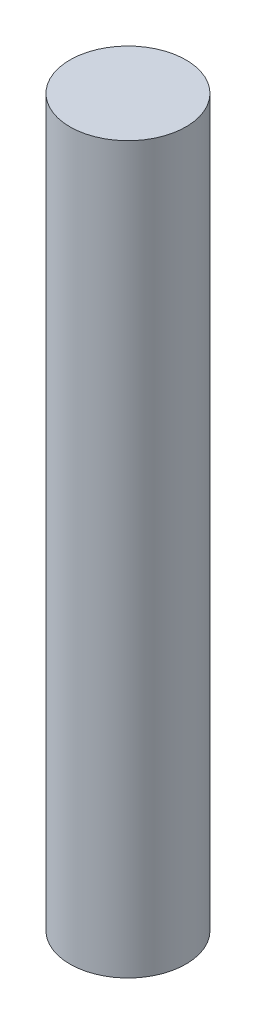
from build123d import *

# Parameters (mm, degrees)
SKETCH1_R           = 6.35
BOSS_EXTRUDE1_DEPTH = 79.375
SKETCH2_R           = 3.889375
CUT_EXTRUDE1_DEPTH  = 31.75


with BuildPart() as part:
    # Sketch1 → Boss-Extrude1 (new body)
    with BuildSketch(Plane(origin=(0, 0, 0), x_dir=(1, 0, 0), z_dir=(0, 1, 0))):
        Circle(SKETCH1_R)
    extrude(amount=BOSS_EXTRUDE1_DEPTH)

    # Sketch2 → Cut-Extrude1 (cut)
    with BuildSketch(Plane(origin=(0, 0, 0), x_dir=(-1, 0, 0), z_dir=(0, -1, 0))):
        Circle(SKETCH2_R)
    extrude(amount=-CUT_EXTRUDE1_DEPTH, mode=Mode.SUBTRACT)


solid = part.part
